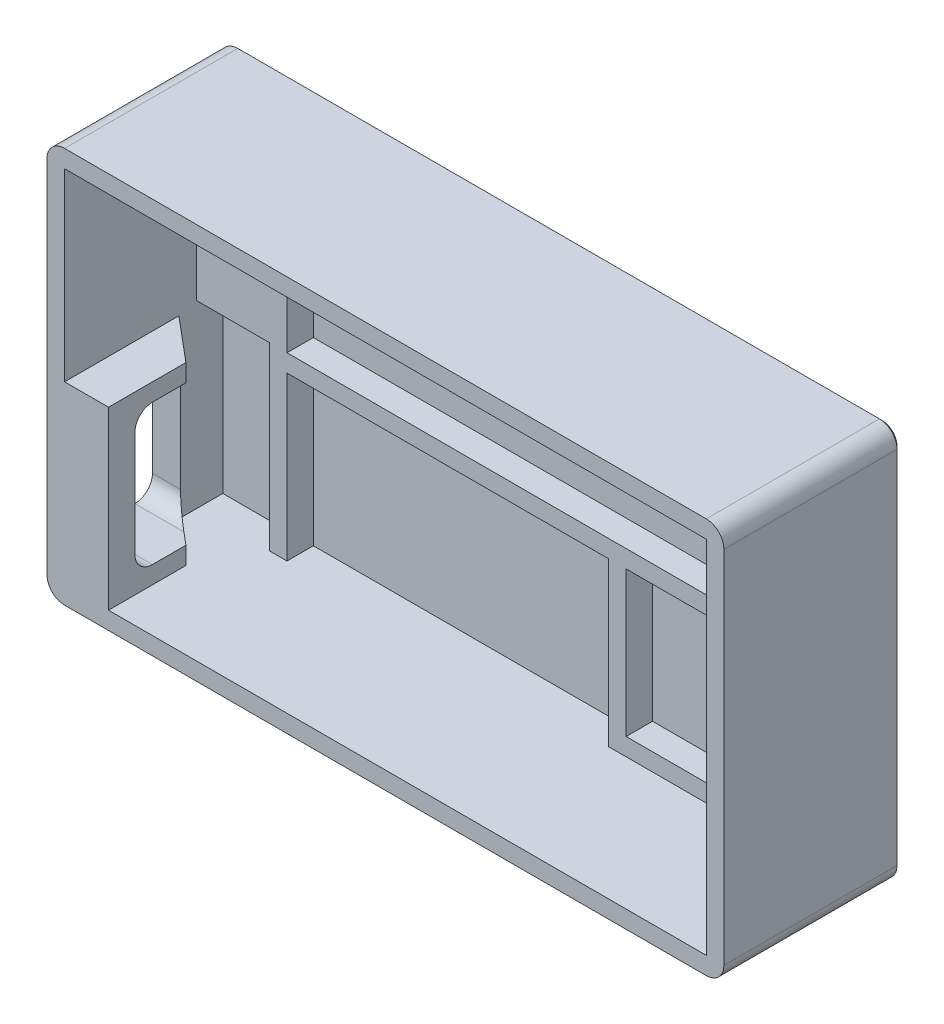
from build123d import *

# Parameters (mm, degrees)
SKETCH2_W           = 77
SKETCH2_H           = 45
SKETCH2_R           = 2.1
BOSS_EXTRUDE2_DEPTH = 20
CUT_EXTRUDE1_DEPTH  = 15
SKETCH4_R           = 2.1
SKETCH4_W           = 52.379694286
SKETCH4_H           = 20.484576037
SKETCH4_W_2         = 36.58107182
SKETCH4_H_2         = 18.515423963
SKETCH4_W_3         = 13.798622466
SKETCH4_H_3         = 16.515423963
SKETCH4_W_4         = 8.316970937
SKETCH4_H_4         = 22.484576037
SKETCH4_W_5         = 8.303334777
SKETCH4_H_5         = 20.515423963
CUT_EXTRUDE2_DEPTH  = 3
CUT_EXTRUDE3_REACH  = 79
FILLET1_R           = 2
CUT_EXTRUDE8_DEPTH  = 20
CHAMFER1_SIZE       = 0.3


with BuildPart() as part:
    # Sketch2 → Boss-Extrude2 (new body)
    with BuildSketch(Plane.XY):
        with Locations((30.99874, -9.99994)):
            Rectangle(SKETCH2_W, SKETCH2_H)
        with Locations((-0.00126, 6e-05)):
            Circle(SKETCH2_R, mode=Mode.SUBTRACT)
        with Locations((61.99874, -19.99994)):
            Circle(SKETCH2_R, mode=Mode.SUBTRACT)
    extrude(amount=BOSS_EXTRUDE2_DEPTH)

    # Sketch3 → Cut-Extrude1 (cut)
    with BuildSketch(Plane.XY.offset(20)):
        Polygon((-5.50126, 10.50006), (67.49874, 10.50006), (67.49874, -30.49994), (-0.50126, -30.49994), (-0.50126, -10.49994), (-5.50126, -10.49994), align=None)
    extrude(amount=-CUT_EXTRUDE1_DEPTH, mode=Mode.SUBTRACT)

    # Sketch4 → Cut-Extrude2 (cut)
    with BuildSketch(Plane.XY.offset(5)):
        with Locations((-0.00126, 6e-05)):
            Circle(SKETCH4_R)
        with Locations((61.99874, -19.99994)):
            Circle(SKETCH4_R)
        with Locations((30.99192192, 0.257771982)):
            Rectangle(SKETCH4_W, SKETCH4_H)
        with Locations((23.092610687, -21.242228019)):
            Rectangle(SKETCH4_W_2, SKETCH4_H_2)
        with Locations((50.28245783, -20.242228019)):
            Rectangle(SKETCH4_W_3, SKETCH4_H_3)
        with Locations((63.340254532, -0.742228018)):
            Rectangle(SKETCH4_W_4, SKETCH4_H_4)
        with Locations((-1.349592612, -20.242228019)):
            Rectangle(SKETCH4_W_5, SKETCH4_H_5)
    extrude(amount=-CUT_EXTRUDE2_DEPTH, mode=Mode.SUBTRACT)

    # Sketch5 → Cut-Extrude3 (cut, up to next)
    with BuildSketch(Plane.ZY.offset(7.50126), mode=Mode.PRIVATE) as cut_extrude3_sk1:
        with BuildLine():
            Line((10, -12.49994), (15, -12.49994))
            ThreePointArc((15, -12.49994), (16.414213562, -13.085726438), (17, -14.49994))
            Line((17, -14.49994), (17, -26.49994))
            ThreePointArc((17, -26.49994), (16.414213562, -27.914153562), (15, -28.49994))
            Line((15, -28.49994), (10, -28.49994))
            ThreePointArc((10, -28.49994), (8.585786438, -27.914153562), (8, -26.49994))
            Line((8, -26.49994), (8, -14.49994))
            ThreePointArc((8, -14.49994), (8.585786438, -13.085726438), (10, -12.49994))
        make_face()
    cut_extrude3_tool1 = extrude(cut_extrude3_sk1.sketch, amount=-CUT_EXTRUDE3_REACH, mode=Mode.PRIVATE) & part.part
    add(cut_extrude3_tool1.solids().sort_by_distance((-7.50126, -20.49994, 12.5))[0], mode=Mode.SUBTRACT)

    # Fillet1
    fillet1_edges = [part.edges().sort_by_distance(p)[0] for p in [
        (-7.50126, 12.50006, 10),
        (69.49874, 12.50006, 10),
        (69.49874, -32.49994, 10),
        (-7.50126, -32.49994, 10),
    ]]
    fillet(fillet1_edges, radius=FILLET1_R)

    # Sketch6 → Cut-Extrude8 (cut)
    with BuildSketch(Plane(origin=(0, -10.49994, 0), x_dir=(1, 0, 0), z_dir=(0, 1, 0))):
        Polygon((-5.50126, -7), (-0.50126, -11.195498156), (-0.50126, -5), (-5.50126, -5), align=None)
    extrude(amount=-CUT_EXTRUDE8_DEPTH, mode=Mode.SUBTRACT)

    # Chamfer1
    chamfer1_edges = [part.edges().sort_by_distance(p)[0] for p in [
        (-2.10126, 6e-05, 0),
        (69.49874, -9.99994, 0),
        (-7.50126, -9.99994, 0),
        (30.99874, 12.50006, 0),
        (30.99874, -32.49994, 0),
        (-6.915473562, -31.914153562, 0),
        (-6.915473562, 11.914273562, 0),
        (68.912953562, 11.914273562, 0),
        (68.912953562, -31.914153562, 0),
        (59.89874, -19.99994, 0),
    ]]
    chamfer(chamfer1_edges, length=CHAMFER1_SIZE)


solid = part.part
